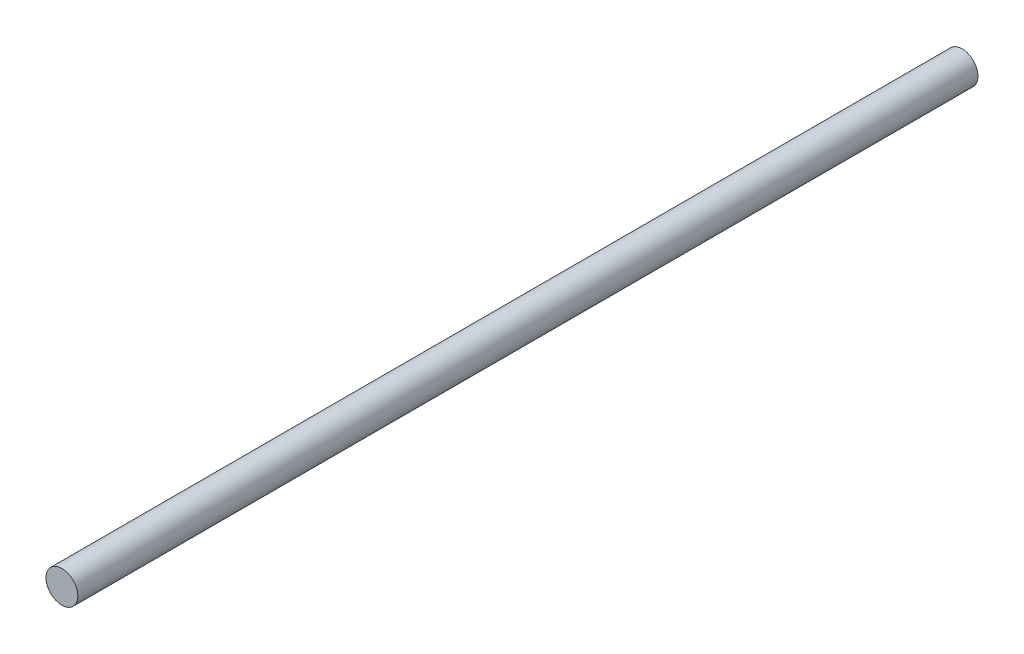
from build123d import *

# Parameters (mm, degrees)
SKETCH1_R           = 6.5
BOSS_EXTRUDE1_DEPTH = 367.475


with BuildPart() as part:
    # Sketch1 → Boss-Extrude1 (new body)
    with BuildSketch(Plane.XY):
        Circle(SKETCH1_R)
    extrude(amount=BOSS_EXTRUDE1_DEPTH)


solid = part.part
